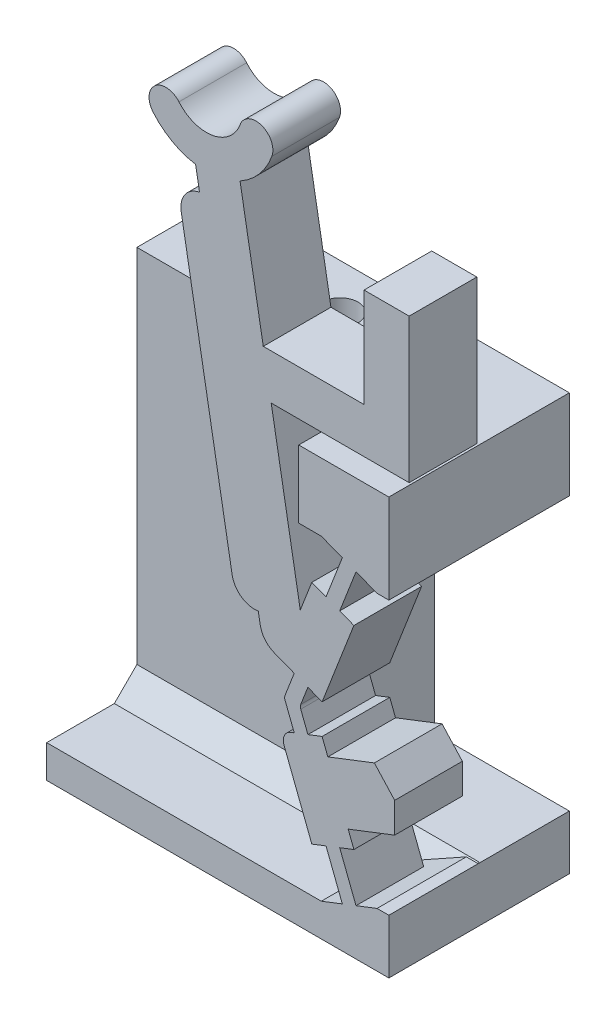
from build123d import *

# Parameters (mm, degrees)
BOSS_SWITCH_BODY_DEPTH            = 3
SKETCH1_W                         = 2.994375291
SKETCH1_H                         = 2.409101515
SKETCH1_W_2                       = 3.994375291
SKETCH1_H_2                       = 3.957767538
BOSS_FLANGE_WIDTH_DEPTH           = 5
BOSS_FLANGE_HEIGHT_REACH          = 36.354
SKETCH2_W                         = 4
SKETCH2_H                         = 3.957767538
SKETCH2_W_2                       = 8
SKETCH2_H_2                       = 1.451333978
SKETCH17_W                        = 15.1675
SKETCH17_H                        = 4
BOSS_FLANGE_SUPPORT_DEPTH         = 13.053634428
CUT_WALL_GAP_DEPTH                = 1
TAP_DRILL_FOR_M2X0_4_TAP1_D       = 1.6
M2_CLEARANCE_HOLE2_D              = 2.4
M2_CLEARANCE_HOLE2_DEPTH          = 13.462735941
CHAMFER_FLANGE_SUPPORT_3_SIZE     = 1
FILLET1_R                         = 1
FILLET2_R                         = 0.5
SKETCH28_W                        = 5.9675
SKETCH28_H                        = 12.095866891
CUT_PRINT_SUPPORT_CLEARANCE_DEPTH = 33.624103931


with BuildPart() as part:
    # Sketch-SwitchBossUp → Boss-Switch Body (new body)
    with BuildSketch(Plane.XY):
        with BuildLine():
            Line((-5.697895702, 26.949658376), (-5.524247524, 25.964850623))
            ThreePointArc((-5.524247524, 25.964850623), (-6.169751391, 25.553619307), (-6.3354071, 24.806394693))
            Line((-6.3354071, 24.806394693), (-4.07798079, 12.003893904))
            ThreePointArc((-4.07798079, 12.003893904), (-3.666749473, 11.358390037), (-2.919524859, 11.192734328))
            Line((-2.919524859, 11.192734328), (-2.734924291, 10.145812481))
            Line((-2.734924291, 10.145812481), (-1.956559213, 9.844099378))
            Line((-1.956559213, 9.844099378), (-1.327187553, 9.600139722))
            Line((-1.327187553, 9.600139722), (-1.735258621, 8.547390389))
            ThreePointArc((-1.735258621, 8.547390389), (-1.752158006, 8.457034961), (-1.735258621, 8.366679532))
            Line((-1.735258621, 8.366679532), (-1.327187553, 7.313930199))
            Line((-1.327187553, 7.313930199), (-1.956559213, 7.069970543))
            Line((-1.956559213, 7.069970543), (-0.547014535, 3.433600952))
            Line((-0.547014535, 3.433600952), (0.082357125, 3.677560608))
            Line((0.082357125, 3.677560608), (0.805200549, 1.81275569))
            Line((0.805200549, 1.81275569), (-0.12720191, 1.451333978))
            Line((-0.12720191, 1.451333978), (-0.12720191, 0))
            Line((-0.12720191, 0), (2.867173381, 0))
            Line((2.867173381, 0), (2.867173381, 2.409101515))
            Line((2.867173381, 2.409101515), (2.343664607, 2.409101515))
            Line((2.343664607, 2.409101515), (1.411262148, 2.047679803))
            Line((1.411262148, 2.047679803), (0.688418723, 3.912484721))
            Line((0.688418723, 3.912484721), (1.317790383, 4.156444377))
            Line((1.317790383, 4.156444377), (1.063052687, 4.813621425))
            Line((1.063052687, 4.813621425), (3.125189653, 5.612955517))
            Line((3.125189653, 5.612955517), (3.125189653, 6.948407561))
            Line((3.125189653, 6.948407561), (2.225005405, 7.93492645))
            Line((2.225005405, 7.93492645), (0.162983401, 7.13563692))
            Line((0.162983401, 7.13563692), (-0.091754295, 7.792813968))
            Line((-0.091754295, 7.792813968), (-0.721125955, 7.548854312))
            Line((-0.721125955, 7.548854312), (-1.038134762, 8.366679532))
            ThreePointArc((-1.038134762, 8.366679532), (-1.055034148, 8.457034961), (-1.038134762, 8.547390389))
            Line((-1.038134762, 8.547390389), (-0.721125955, 9.365215609))
            Line((-0.721125955, 9.365215609), (-0.091754295, 9.121255953))
            Line((-0.091754295, 9.121255953), (1.317790383, 12.757625544))
            Line((1.317790383, 12.757625544), (0.688418723, 13.0015852))
            Line((0.688418723, 13.0015852), (1.411262148, 14.866390118))
            Line((1.411262148, 14.866390118), (2.343664607, 14.504968406))
            Line((2.343664607, 14.504968406), (2.867173381, 14.504968406))
            Line((2.867173381, 14.504968406), (2.867173381, 18.462735944))
            Line((2.867173381, 18.462735944), (-0.111637615, 18.462735944))
            Line((-0.111637615, 18.462735944), (-1.12720191, 18.462735944))
            Line((-1.12720191, 18.462735944), (-1.12720191, 15.462735944))
            Line((-1.12720191, 15.462735944), (-0.12720191, 15.462735944))
            Line((-0.12720191, 15.462735944), (0.805200549, 15.101314231))
            Line((0.805200549, 15.101314231), (0.082357125, 13.236509313))
            Line((0.082357125, 13.236509313), (-0.547014535, 13.480468969))
            Line((-0.547014535, 13.480468969), (-1.059112089, 12.159350171))
            Line((-1.059112089, 12.159350171), (-2.346896051, 19.462735944))
            Line((-2.346896051, 19.462735944), (3.767173381, 19.462735944))
            Line((3.767173381, 19.462735944), (3.767173381, 25.857619356))
            Line((3.767173381, 25.857619356), (1.767173381, 25.857619356))
            Line((1.767173381, 25.857619356), (1.767173381, 21.462735944))
            Line((1.767173381, 21.462735944), (-2.699550012, 21.462735944))
            Line((-2.699550012, 21.462735944), (-3.728280196, 27.296954732))
            ThreePointArc((-3.728280196, 27.296954732), (-2.874356585, 27.992742953), (-2.319025652, 28.944012807))
            ThreePointArc((-2.319025652, 28.944012807), (-2.76728001, 29.905297381), (-3.728564583, 29.457043022))
            ThreePointArc((-3.728564583, 29.457043022), (-4.944660137, 28.436617692), (-6.436422172, 28.97957467))
            ThreePointArc((-6.436422172, 28.97957467), (-7.493046212, 29.072017295), (-7.585488837, 28.015393255))
            ThreePointArc((-7.585488837, 28.015393255), (-6.738295005, 27.311426358), (-5.697895702, 26.949658376))
        make_face()
    extrude(amount=BOSS_SWITCH_BODY_DEPTH)

    # Sketch1 → Boss-Flange Width (add)
    with BuildSketch(Plane(origin=(0, 0, 0), x_dir=(-1, 0, 0), z_dir=(0, 0, -1))):
        with Locations((-1.369985736, 1.204550758)):
            Rectangle(SKETCH1_W, SKETCH1_H)
        with Locations((-0.869985736, 16.483852175)):
            Rectangle(SKETCH1_W_2, SKETCH1_H_2)
    extrude(amount=BOSS_FLANGE_WIDTH_DEPTH)

    # Boss-Flange Height: up to this face of the body (flat: up to its plane)
    boss_flange_height_end = Plane(part.part.faces().sort_by_distance((-0.12720191, 1.077409098, -1.438016547))[0])
    # Sketch2 → Boss-Flange Height (add, up to the picked face)
    with BuildSketch(Plane(origin=(-12.300326619, 0, 0), x_dir=(0, 0, -1), z_dir=(1, 0, 0)), mode=Mode.PRIVATE) as boss_flange_height_sk1:
        with Locations((3, 16.483852175)):
            Rectangle(SKETCH2_W, SKETCH2_H)
    boss_flange_height_tool1 = split(extrude(boss_flange_height_sk1.sketch, amount=BOSS_FLANGE_HEIGHT_REACH, mode=Mode.PRIVATE), bisect_by=boss_flange_height_end, keep=Keep.BOTH, mode=Mode.PRIVATE)
    # Sketch2 → Boss-Flange Height (add, up to the picked face)
    with BuildSketch(Plane(origin=(-12.300326619, 0, 0), x_dir=(0, 0, -1), z_dir=(1, 0, 0)), mode=Mode.PRIVATE) as boss_flange_height_sk2:
        with Locations((1, 0.725666989)):
            Rectangle(SKETCH2_W_2, SKETCH2_H_2)
    boss_flange_height_tool2 = split(extrude(boss_flange_height_sk2.sketch, amount=BOSS_FLANGE_HEIGHT_REACH, mode=Mode.PRIVATE), bisect_by=boss_flange_height_end, keep=Keep.BOTH, mode=Mode.PRIVATE)
    add(boss_flange_height_tool1.solids().sort_by(Axis((-12.300327, 16.483852, -3), (1, 0, 0)))[0])
    add(boss_flange_height_tool2.solids().sort_by(Axis((-12.300327, 0.725667, -1), (1, 0, 0)))[0])

    # Sketch17 → Boss-Flange Support (add)
    with BuildSketch(Plane.XZ.offset(-1.451333978)):
        with Locations((-4.716576619, -3)):
            Rectangle(SKETCH17_W, SKETCH17_H)
    extrude(amount=-BOSS_FLANGE_SUPPORT_DEPTH)

    # Sketch27 → Cut-Wall Gap (cut)
    with BuildSketch(Plane.XY):
        Polygon((-0.12720191, 15.462735944), (2.343664607, 14.504968406), (-1.12720191, 14.504968406), (-1.12720191, 15.462735944), align=None)
        Polygon((2.343664607, 2.409101515), (-0.12720191, 2.409101515), (-0.12720191, 1.451333978), align=None)
    extrude(amount=-CUT_WALL_GAP_DEPTH, mode=Mode.SUBTRACT)

    # Tap Drill for M2x0.4 Tap1 (through all)
    with Locations(Plane(origin=(0, 0, 0), x_dir=(-1, 0, 0), z_dir=(0, -1, 0))):
        with Locations((9.300326619, 3), (5.300326619, 3)):
            Hole(TAP_DRILL_FOR_M2X0_4_TAP1_D / 2)

    # M2 Clearance Hole2
    with Locations(Plane.XZ):
        with Locations((-9.300326619, -3), (-5.300326619, -3)):
            Hole(M2_CLEARANCE_HOLE2_D / 2, depth=M2_CLEARANCE_HOLE2_DEPTH)

    # Chamfer-Flange Support 3
    chamfer_flange_support_3_edges = [part.edges().sort_by_distance(p)[0] for p in [
        (-6.213764264, 1.451333978, -1),
    ]]
    chamfer(chamfer_flange_support_3_edges, length=CHAMFER_FLANGE_SUPPORT_3_SIZE)

    # Fillet1
    fillet1_edges = [part.edges().sort_by_distance(p)[0] for p in [
        (-2.734924291, 10.145812481, 1.5),
    ]]
    fillet(fillet1_edges, radius=FILLET1_R)

    # Fillet2
    fillet2_edges = [part.edges().sort_by_distance(p)[0] for p in [
        (-1.956559213, 7.069970543, 1.5),
    ]]
    fillet(fillet2_edges, radius=FILLET2_R)

    # Sketch28 → Cut-Print Support Clearance (cut, through all)
    with BuildSketch(Plane.XY.offset(-1)):
        with Locations((-0.116576619, 8.457034961)):
            Rectangle(SKETCH28_W, SKETCH28_H)
    extrude(amount=-CUT_PRINT_SUPPORT_CLEARANCE_DEPTH, mode=Mode.SUBTRACT)


solid = part.part
